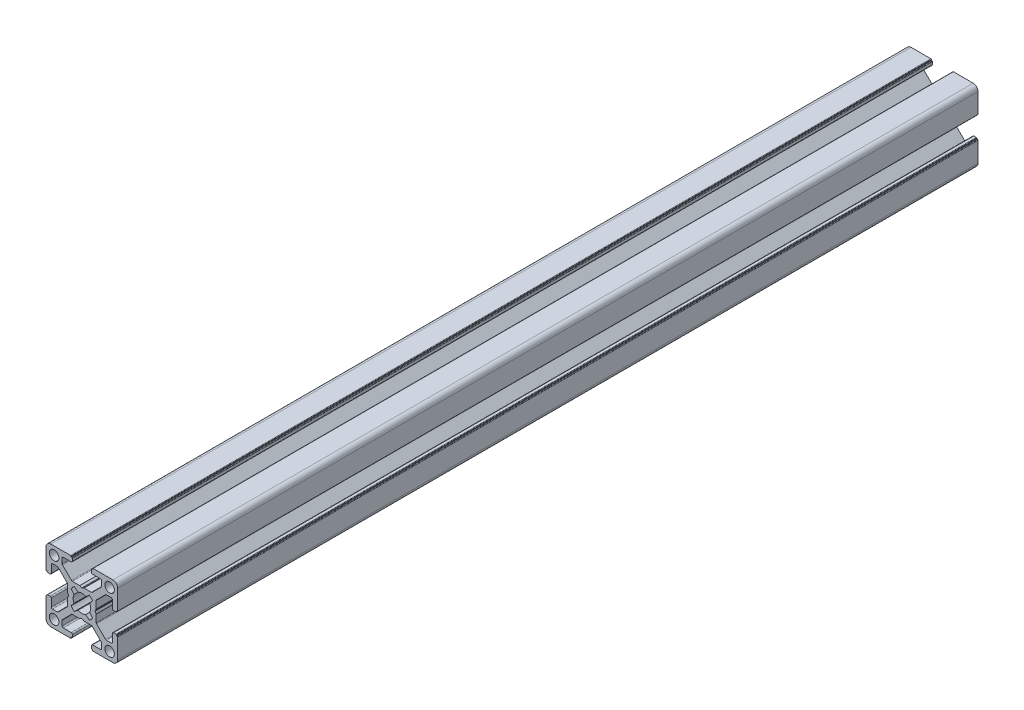
from build123d import *

# Parameters (mm, degrees)
CROQUIS1_R              = 2
SALIENTE_EXTRUIR1_DEPTH = 360


with BuildPart() as part:
    # Croquis1 → Saliente-Extruir1 (new body)
    with BuildSketch(Plane.XY.offset(1000)):
        with BuildLine():
            Line((9.800000436, -10.500000436), (10.100000436, -10.500000436))
            ThreePointArc((10.100000436, -10.500000436), (10.241421792, -10.441421792), (10.300000436, -10.300000436))
            Line((10.300000436, -10.300000436), (10.300000436, -2))
            ThreePointArc((10.300000436, -2), (9.714213998, -0.585786438), (8.300000436, 0))
            Line((8.300000436, 0), (0, 0))
            ThreePointArc((0, 0), (-0.141421356, -0.058578644), (-0.2, -0.2))
            Line((-0.2, -0.2), (-0.2, -0.5))
            Line((-0.2, -0.5), (-0.49999919, -0.5))
            ThreePointArc((-0.49999919, -0.5), (-0.641420811, -0.558578753), (-0.699999564, -0.700000374))
            Line((-0.699999564, -0.700000374), (-0.699999564, -1.700000763))
            ThreePointArc((-0.699999564, -1.700000763), (-0.553552955, -2.053554154), (-0.199999564, -2.200000763))
            Line((-0.199999564, -2.200000763), (3.050000763, -2.200000763))
            ThreePointArc((3.050000763, -2.200000763), (3.403554154, -2.346447372), (3.550000763, -2.700000763))
            Line((3.550000763, -2.700000763), (3.550000763, -4.743055509))
            ThreePointArc((3.550000763, -4.743055509), (3.511993279, -4.934269826), (3.403749103, -5.096413843))
            Line((3.403749103, -5.096413843), (-0.349053376, -8.853358334))
            ThreePointArc((-0.349053376, -8.853358334), (-0.511332616, -8.961886981), (-0.702801716, -9))
            Line((-0.702801716, -9), (-3.746809419, -9))
            ThreePointArc((-3.746809419, -9), (-3.798212795, -9.006718618), (-3.846162576, -9.026423071))
            Line((-3.846162576, -9.026423071), (-4.600646407, -9.458279719))
            ThreePointArc((-4.600646407, -9.458279719), (-4.699999564, -9.48470279), (-4.799352721, -9.458279719))
            Line((-4.799352721, -9.458279719), (-5.553836552, -9.026423071))
            ThreePointArc((-5.553836552, -9.026423071), (-5.601786333, -9.006718618), (-5.653189709, -9))
            Line((-5.653189709, -9), (-8.697197412, -9))
            ThreePointArc((-8.697197412, -9), (-8.888666513, -8.961886981), (-9.050945752, -8.853358334))
            Line((-9.050945752, -8.853358334), (-12.803748231, -5.096413843))
            ThreePointArc((-12.803748231, -5.096413843), (-12.911992407, -4.934269826), (-12.949999891, -4.743055509))
            Line((-12.949999891, -4.743055509), (-12.949999891, -2.700000763))
            ThreePointArc((-12.949999891, -2.700000763), (-12.803553282, -2.346447372), (-12.449999891, -2.200000763))
            Line((-12.449999891, -2.200000763), (-9.199999564, -2.200000763))
            ThreePointArc((-9.199999564, -2.200000763), (-8.846446173, -2.053554154), (-8.699999564, -1.700000763))
            Line((-8.699999564, -1.700000763), (-8.699999564, -0.700000374))
            ThreePointArc((-8.699999564, -0.700000374), (-8.758578317, -0.558578753), (-8.899999938, -0.5))
            Line((-8.899999938, -0.5), (-9.199999128, -0.5))
            Line((-9.199999128, -0.5), (-9.199999128, -0.2))
            ThreePointArc((-9.199999128, -0.2), (-9.258577772, -0.058578644), (-9.399999128, 0))
            Line((-9.399999128, 0), (-17.699999564, 0))
            ThreePointArc((-17.699999564, 0), (-19.114213126, -0.585786438), (-19.699999564, -2))
            Line((-19.699999564, -2), (-19.699999564, -10.300000436))
            ThreePointArc((-19.699999564, -10.300000436), (-19.64142092, -10.441421792), (-19.499999564, -10.500000436))
            Line((-19.499999564, -10.500000436), (-19.199999564, -10.500000436))
            Line((-19.199999564, -10.500000436), (-19.199999564, -10.799999627))
            ThreePointArc((-19.199999564, -10.799999627), (-19.141420811, -10.941421247), (-18.99999919, -11))
            Line((-18.99999919, -11), (-17.999998801, -11))
            ThreePointArc((-17.999998801, -11), (-17.64644541, -10.853553391), (-17.499998801, -10.5))
            Line((-17.499998801, -10.5), (-17.499998801, -7.249999673))
            ThreePointArc((-17.499998801, -7.249999673), (-17.353552192, -6.896446283), (-16.999998801, -6.749999673))
            Line((-16.999998801, -6.749999673), (-14.956944055, -6.749999673))
            ThreePointArc((-14.956944055, -6.749999673), (-14.765729738, -6.788007157), (-14.603585721, -6.896251334))
            Line((-14.603585721, -6.896251334), (-10.84664123, -10.649053813))
            ThreePointArc((-10.84664123, -10.649053813), (-10.738112583, -10.811333052), (-10.699999564, -11.002802152))
            Line((-10.699999564, -11.002802152), (-10.699999564, -14.046809855))
            ThreePointArc((-10.699999564, -14.046809855), (-10.693280947, -14.098213232), (-10.673576493, -14.146163012))
            Line((-10.673576493, -14.146163012), (-10.241719845, -14.900646843))
            ThreePointArc((-10.241719845, -14.900646843), (-10.215296774, -15), (-10.241719845, -15.099353157))
            Line((-10.241719845, -15.099353157), (-10.673576493, -15.853836988))
            ThreePointArc((-10.673576493, -15.853836988), (-10.693280947, -15.901786769), (-10.699999564, -15.953190146))
            Line((-10.699999564, -15.953190146), (-10.699999564, -18.997197848))
            ThreePointArc((-10.699999564, -18.997197848), (-10.738112583, -19.188666949), (-10.84664123, -19.350946188))
            Line((-10.84664123, -19.350946188), (-14.603585721, -23.103748667))
            ThreePointArc((-14.603585721, -23.103748667), (-14.765729738, -23.211992843), (-14.956944055, -23.250000327))
            Line((-14.956944055, -23.250000327), (-16.999998801, -23.250000327))
            ThreePointArc((-16.999998801, -23.250000327), (-17.353552192, -23.103553718), (-17.499998801, -22.750000327))
            Line((-17.499998801, -22.750000327), (-17.499998801, -19.5))
            ThreePointArc((-17.499998801, -19.5), (-17.64644541, -19.14644661), (-17.999998801, -19))
            Line((-17.999998801, -19), (-18.99999919, -19))
            ThreePointArc((-18.99999919, -19), (-19.141420811, -19.058578753), (-19.199999564, -19.200000374))
            Line((-19.199999564, -19.200000374), (-19.199999564, -19.499999564))
            Line((-19.199999564, -19.499999564), (-19.499999564, -19.499999564))
            ThreePointArc((-19.499999564, -19.499999564), (-19.64142092, -19.558578208), (-19.699999564, -19.699999564))
            Line((-19.699999564, -19.699999564), (-19.699999564, -28))
            ThreePointArc((-19.699999564, -28), (-19.114213126, -29.414213563), (-17.699999564, -30))
            Line((-17.699999564, -30), (-9.399999128, -30))
            ThreePointArc((-9.399999128, -30), (-9.258577772, -29.941421356), (-9.199999128, -29.8))
            Line((-9.199999128, -29.8), (-9.199999128, -29.5))
            Line((-9.199999128, -29.5), (-8.899999938, -29.5))
            ThreePointArc((-8.899999938, -29.5), (-8.758578317, -29.441421247), (-8.699999564, -29.299999627))
            Line((-8.699999564, -29.299999627), (-8.699999564, -28.299999237))
            ThreePointArc((-8.699999564, -28.299999237), (-8.846446173, -27.946445847), (-9.199999564, -27.799999237))
            Line((-9.199999564, -27.799999237), (-12.449999891, -27.799999237))
            ThreePointArc((-12.449999891, -27.799999237), (-12.803553282, -27.653552628), (-12.949999891, -27.299999237))
            Line((-12.949999891, -27.299999237), (-12.949999891, -25.256944491))
            ThreePointArc((-12.949999891, -25.256944491), (-12.911992407, -25.065730174), (-12.803748231, -24.903586157))
            Line((-12.803748231, -24.903586157), (-9.050945752, -21.146641666))
            ThreePointArc((-9.050945752, -21.146641666), (-8.888666513, -21.038113019), (-8.697197412, -21))
            Line((-8.697197412, -21), (-5.653189709, -21))
            ThreePointArc((-5.653189709, -21), (-5.601786333, -20.993281383), (-5.553836552, -20.973576929))
            Line((-5.553836552, -20.973576929), (-4.799352721, -20.541720281))
            ThreePointArc((-4.799352721, -20.541720281), (-4.699999564, -20.51529721), (-4.600646407, -20.541720281))
            Line((-4.600646407, -20.541720281), (-3.846162576, -20.973576929))
            ThreePointArc((-3.846162576, -20.973576929), (-3.798212795, -20.993281383), (-3.746809419, -21))
            Line((-3.746809419, -21), (-0.702801716, -21))
            ThreePointArc((-0.702801716, -21), (-0.511332616, -21.038113019), (-0.349053377, -21.146641666))
            Line((-0.349053377, -21.146641666), (3.403749103, -24.903586157))
            ThreePointArc((3.403749103, -24.903586157), (3.511993279, -25.065730174), (3.550000763, -25.256944491))
            Line((3.550000763, -25.256944491), (3.550000763, -27.299999237))
            ThreePointArc((3.550000763, -27.299999237), (3.403554154, -27.653552628), (3.050000763, -27.799999237))
            Line((3.050000763, -27.799999237), (-0.199999564, -27.799999237))
            ThreePointArc((-0.199999564, -27.799999237), (-0.553552955, -27.946445847), (-0.699999564, -28.299999237))
            Line((-0.699999564, -28.299999237), (-0.699999564, -29.299999627))
            ThreePointArc((-0.699999564, -29.299999627), (-0.641420811, -29.441421247), (-0.49999919, -29.5))
            Line((-0.49999919, -29.5), (-0.2, -29.5))
            Line((-0.2, -29.5), (-0.2, -29.8))
            ThreePointArc((-0.2, -29.8), (-0.141421356, -29.941421356), (0, -30))
            Line((0, -30), (8.300000436, -30))
            ThreePointArc((8.300000436, -30), (9.714213998, -29.414213563), (10.300000436, -28))
            Line((10.300000436, -28), (10.300000436, -19.699999564))
            ThreePointArc((10.300000436, -19.699999564), (10.241421792, -19.558578208), (10.100000436, -19.499999564))
            Line((10.100000436, -19.499999564), (9.800000436, -19.499999564))
            Line((9.800000436, -19.499999564), (9.800000436, -19.200000374))
            ThreePointArc((9.800000436, -19.200000374), (9.741421683, -19.058578753), (9.600000062, -19))
            Line((9.600000062, -19), (8.599999673, -19))
            ThreePointArc((8.599999673, -19), (8.246446283, -19.14644661), (8.099999673, -19.5))
            Line((8.099999673, -19.5), (8.099999673, -22.750000327))
            ThreePointArc((8.099999673, -22.750000327), (7.953553064, -23.103553718), (7.599999673, -23.250000327))
            Line((7.599999673, -23.250000327), (5.556944927, -23.250000327))
            ThreePointArc((5.556944927, -23.250000327), (5.36573061, -23.211992843), (5.203586593, -23.103748667))
            Line((5.203586593, -23.103748667), (1.446642102, -19.350946188))
            ThreePointArc((1.446642102, -19.350946188), (1.338113455, -19.188666949), (1.300000436, -18.997197848))
            Line((1.300000436, -18.997197848), (1.300000436, -15.953190145))
            ThreePointArc((1.300000436, -15.953190145), (1.293281819, -15.901786769), (1.273577365, -15.853836988))
            Line((1.273577365, -15.853836988), (0.841720717, -15.099353157))
            ThreePointArc((0.841720717, -15.099353157), (0.815297646, -15), (0.841720717, -14.900646843))
            Line((0.841720717, -14.900646843), (1.273577365, -14.146163012))
            ThreePointArc((1.273577365, -14.146163012), (1.293281819, -14.098213231), (1.300000436, -14.046809855))
            Line((1.300000436, -14.046809855), (1.300000436, -11.002802152))
            ThreePointArc((1.300000436, -11.002802152), (1.338113455, -10.811333052), (1.446642102, -10.649053813))
            Line((1.446642102, -10.649053813), (5.203586593, -6.896251334))
            ThreePointArc((5.203586593, -6.896251334), (5.36573061, -6.788007157), (5.556944927, -6.749999673))
            Line((5.556944927, -6.749999673), (7.599999673, -6.749999673))
            ThreePointArc((7.599999673, -6.749999673), (7.953553064, -6.896446283), (8.099999673, -7.249999673))
            Line((8.099999673, -7.249999673), (8.099999673, -10.5))
            ThreePointArc((8.099999673, -10.5), (8.246446283, -10.853553391), (8.599999673, -11))
            Line((8.599999673, -11), (9.600000062, -11))
            ThreePointArc((9.600000062, -11), (9.741421683, -10.941421247), (9.800000436, -10.799999627))
            Line((9.800000436, -10.799999627), (9.800000436, -10.500000436))
        make_face()
        with Locations((-16.300000272, -3.399999983)):
            Circle(CROQUIS1_R, mode=Mode.SUBTRACT)
        with Locations((6.900001145, -3.399999983)):
            Circle(CROQUIS1_R, mode=Mode.SUBTRACT)
        with Locations((-16.300000272, -26.600000017)):
            Circle(CROQUIS1_R, mode=Mode.SUBTRACT)
        with Locations((6.900001145, -26.600000017)):
            Circle(CROQUIS1_R, mode=Mode.SUBTRACT)
        with BuildLine():
            Line((-7.835928976, -10.481599097), (-6.300129088, -11.719438233))
            ThreePointArc((-6.300129088, -11.719438233), (-4.699999564, -11.35), (-3.09987004, -11.719438233))
            Line((-3.09987004, -11.719438233), (-1.564070152, -10.481599097))
            ThreePointArc((-1.564070152, -10.481599097), (-0.818997305, -11.10284444), (-0.194662672, -11.845330527))
            Line((-0.194662672, -11.845330527), (-1.419437832, -13.399870404))
            ThreePointArc((-1.419437832, -13.399870404), (-1.049999564, -15), (-1.419437832, -16.600129597))
            Line((-1.419437832, -16.600129597), (-0.194662672, -18.154669473))
            ThreePointArc((-0.194662672, -18.154669473), (-0.818997305, -18.897155561), (-1.564070152, -19.518400903))
            Line((-1.564070152, -19.518400903), (-3.09987004, -18.280561767))
            ThreePointArc((-3.09987004, -18.280561767), (-4.699999564, -18.65), (-6.300129088, -18.280561767))
            Line((-6.300129088, -18.280561767), (-7.835928976, -19.518400903))
            ThreePointArc((-7.835928976, -19.518400903), (-8.581001823, -18.897155561), (-9.205336456, -18.154669473))
            Line((-9.205336456, -18.154669473), (-7.980561295, -16.600129597))
            ThreePointArc((-7.980561295, -16.600129597), (-8.349999564, -15), (-7.980561296, -13.399870404))
            Line((-7.980561296, -13.399870404), (-9.205336456, -11.845330527))
            ThreePointArc((-9.205336456, -11.845330527), (-8.581001823, -11.10284444), (-7.835928976, -10.481599097))
        make_face(mode=Mode.SUBTRACT)
    extrude(amount=-SALIENTE_EXTRUIR1_DEPTH)


solid = part.part
